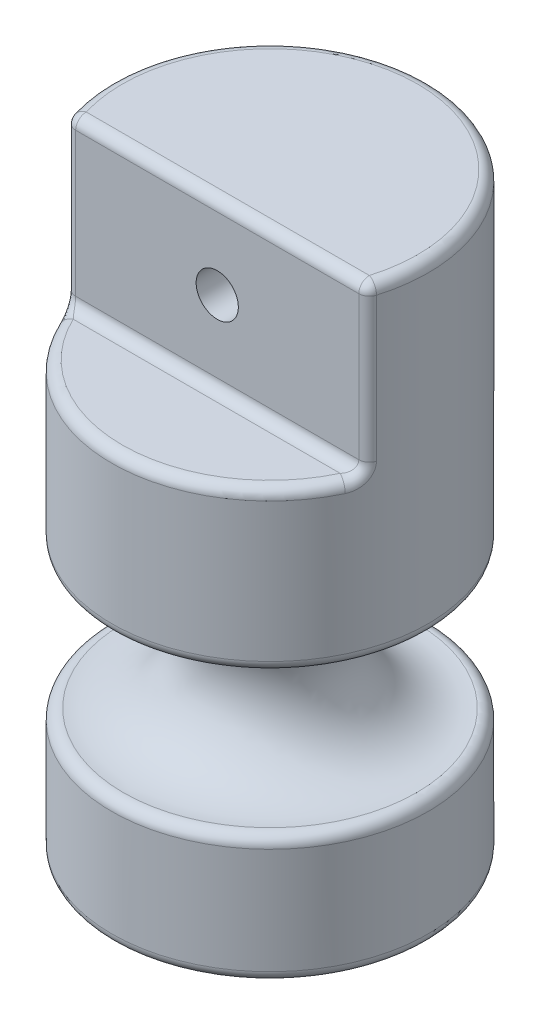
from build123d import *

# Parameters (mm, degrees)
SKETCH1_R                        = 7.62
BOSS_EXTRUDE1_DEPTH              = 28.575
SKETCH3_W                        = 15.24
SKETCH3_H                        = 7.9375
CUT_EXTRUDE1_DEPTH               = 6.08
F_4_0_209_DIAMETER_HOLE1_D       = 2.032
F_4_0_209_DIAMETER_HOLE1_DEPTH   = 6.35
F_4_0_209_DIAMETER_HOLE1_TIP     = 0.610474389
F_10_0_1935_DIAMETER_HOLE1_D     = 3.556
F_10_0_1935_DIAMETER_HOLE1_DEPTH = 6.35
F_10_0_1935_DIAMETER_HOLE1_TIP   = 1.068330181
FILLET1_R                        = 0.508


with BuildPart() as part:
    # Sketch1 → Boss-Extrude1 (new body)
    with BuildSketch(Plane(origin=(0, 0, 0), x_dir=(1, 0, 0), z_dir=(0, 1, 0))):
        Circle(SKETCH1_R)
    extrude(amount=BOSS_EXTRUDE1_DEPTH)

    # Sketch2 → Cut-Revolve1 (revolve, cut)
    with BuildSketch(Plane.XY):
        with BuildLine():
            ThreePointArc((-7.62, 6.223), (-3.266426044, 9.525), (-7.62, 12.827))
            Line((-7.62, 12.827), (-7.62, 6.223))
        make_face()
    revolve(axis=Axis((0, 28.575, 0), (0, -1, 0)), mode=Mode.SUBTRACT)

    # Sketch3 → Cut-Extrude1 (cut, through all)
    with BuildSketch(Plane.XY.offset(2.54)):
        with Locations((0, 24.60625)):
            Rectangle(SKETCH3_W, SKETCH3_H)
    extrude(amount=CUT_EXTRUDE1_DEPTH, mode=Mode.SUBTRACT)

    # #4 (0.209) Diameter Hole1
    with Locations(Plane.XY.offset(2.54)):
        with Locations((0, 24.60625)):
            Hole(F_4_0_209_DIAMETER_HOLE1_D / 2, depth=F_4_0_209_DIAMETER_HOLE1_DEPTH)
            with Locations((0, 0, -(F_4_0_209_DIAMETER_HOLE1_DEPTH + F_4_0_209_DIAMETER_HOLE1_TIP / 2))):  # 118° drill point
                Cone(0, F_4_0_209_DIAMETER_HOLE1_D / 2, F_4_0_209_DIAMETER_HOLE1_TIP, mode=Mode.SUBTRACT)

    # #10 (0.1935) Diameter Hole1
    with Locations(Plane(origin=(0, 0, 0), x_dir=(-1, 0, 0), z_dir=(0, -1, 0))):
        with Locations((0, 0)):
            Hole(F_10_0_1935_DIAMETER_HOLE1_D / 2, depth=F_10_0_1935_DIAMETER_HOLE1_DEPTH)
            with Locations((0, 0, -(F_10_0_1935_DIAMETER_HOLE1_DEPTH + F_10_0_1935_DIAMETER_HOLE1_TIP / 2))):  # 118° drill point
                Cone(0, F_10_0_1935_DIAMETER_HOLE1_D / 2, F_10_0_1935_DIAMETER_HOLE1_TIP, mode=Mode.SUBTRACT)

    # Fillet1
    fillet1_edges = [part.edges().sort_by_distance(p)[0] for p in [
        (-1.288557078, 28.575, -7.510261025),
        (0, 28.575, 2.54),
        (0, 20.6375, 7.62),
        (0, 20.6375, 2.54),
        (7.184204897, 24.60625, 2.54),
        (-7.184204897, 24.60625, 2.54),
        (-7.62, 0, 0),
        (0, 6.223, 7.62),
        (0, 12.827, 7.62),
    ]]
    fillet(fillet1_edges, radius=FILLET1_R)


solid = part.part
